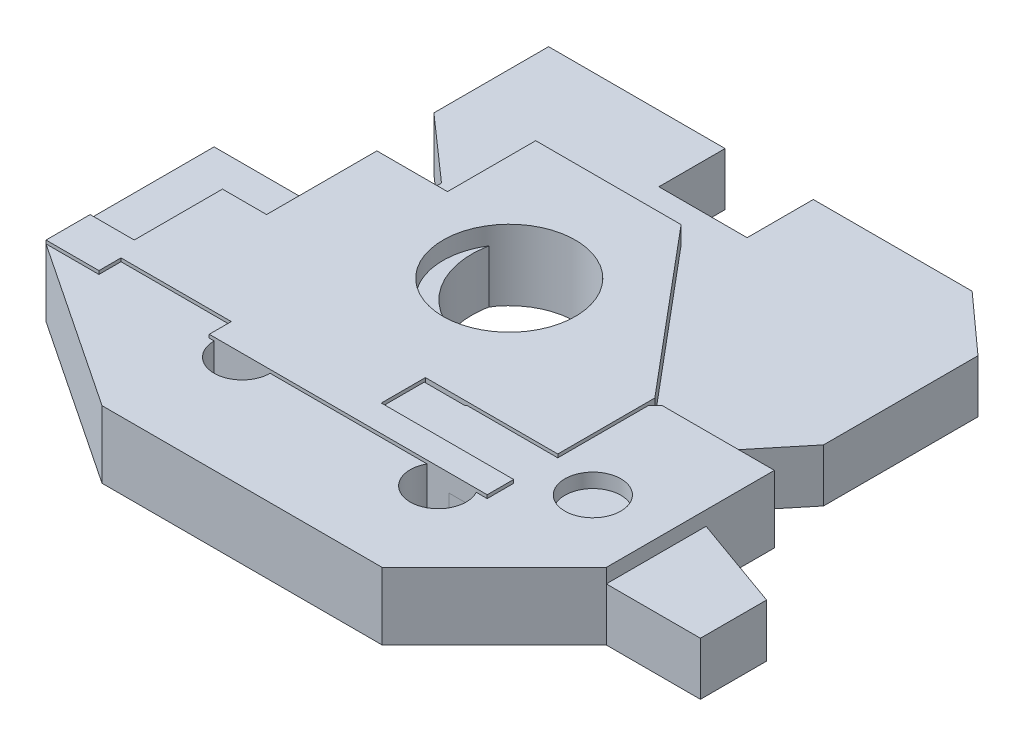
from build123d import *

# Parameters (mm, degrees)
SKETCH1_R           = 18
BOSS_EXTRUDE1_DEPTH = 12
SKETCH3_R           = 6.35
BOSS_EXTRUDE2_DEPTH = 15.24
SKETCH5_R           = 15
BOSS_EXTRUDE3_DEPTH = 16


with BuildPart() as part:
    # Sketch1 → Boss-Extrude1 (new body)
    with BuildSketch(Plane(origin=(0, 0, 0), x_dir=(1, 0, 0), z_dir=(0, 1, 0))):
        Polygon((0, 0), (50, 0), (44, 9.42), (97.33, 9.42), (91.33, 0), (148.33, 0), (148.33, 15), (106.33, 30), (124.33, 51.92), (124.33, 86.92), (111, 98.92), (75, 98.92), (75, 83.92), (55, 83.92), (55, 98.92), (15, 98.92), (15, 72.92), (29.644658559, 60), (29.644658559, 40), (12, 20), (0, 20), align=None)
        with Locations((65, 49.5)):
            Circle(SKETCH1_R, mode=Mode.SUBTRACT)
    extrude(amount=BOSS_EXTRUDE1_DEPTH)


with BuildPart() as body_2:
    # Sketch3 → Boss-Extrude2 (new body)
    with BuildSketch(Plane(origin=(0, 0, 0), x_dir=(1, 0, 0), z_dir=(0, 1, 0))):
        Polygon((0, 0), (0, 38.1), (25.4, 38.1), (47.752, 15.748), (79.248, 15.748), (101.6, 38.1), (127, 38.1), (127, 0), (101.6, -25.4), (38.1, -25.4), align=None)
        with Locations((19.05, 19.05)):
            Circle(SKETCH3_R, mode=Mode.SUBTRACT)
        with Locations((44.45, 0)):
            Circle(SKETCH3_R, mode=Mode.SUBTRACT)
        with Locations((91.948, -3.048)):
            Circle(SKETCH3_R, mode=Mode.SUBTRACT)
        with Locations((111.252, 12.7)):
            Circle(SKETCH3_R, mode=Mode.SUBTRACT)
    extrude(amount=BOSS_EXTRUDE2_DEPTH)


with BuildPart() as body_3:
    # Sketch5 → Boss-Extrude3 (new body)
    with BuildSketch(Plane(origin=(0, 0, 0), x_dir=(1, 0, 0), z_dir=(0, 1, 0))):
        Polygon((0, 0), (12, 0), (12, 5), (37, 5), (37, 0), (100, 0), (100, 6), (70, 6), (70, 16), (100, 16), (100, 38), (68.953313646, 75), (36, 75), (36, 55), (20, 55), (20, 30), (10, 30), (10, 10), (0, 10), align=None)
        with Locations((60, 45)):
            Circle(SKETCH5_R, mode=Mode.SUBTRACT)
    extrude(amount=BOSS_EXTRUDE3_DEPTH)


solid = Compound([part.part, body_2.part, body_3.part])
